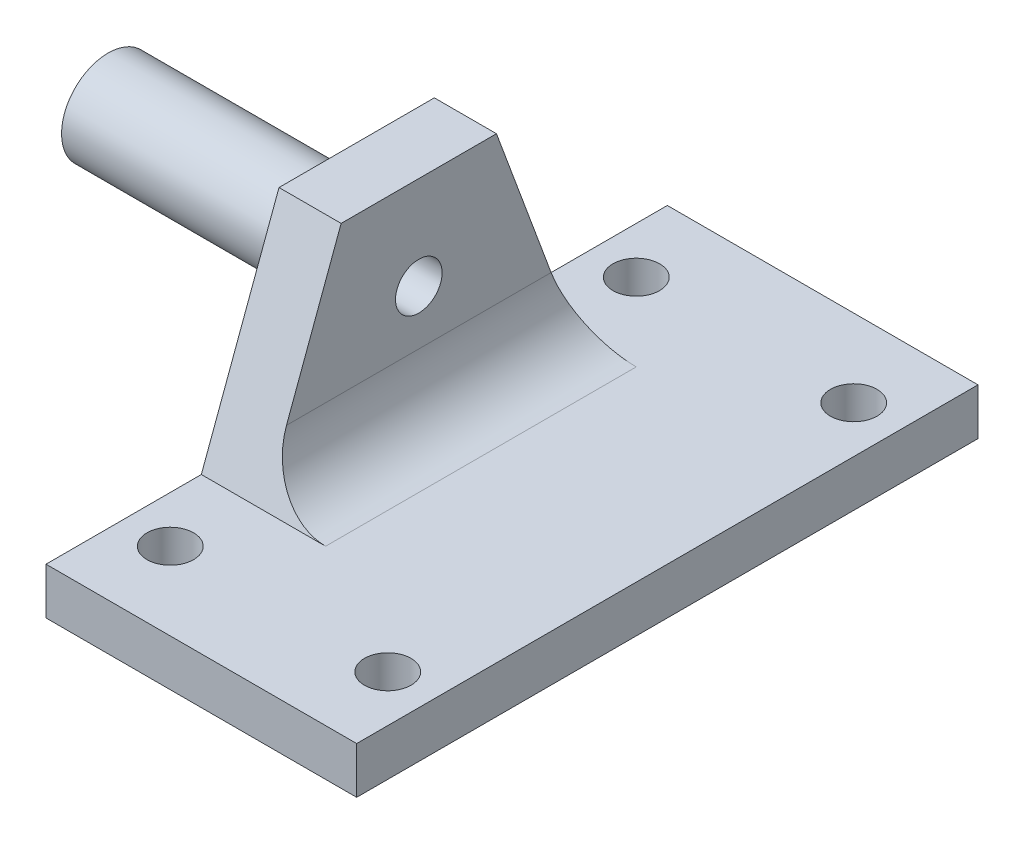
from build123d import *

# Parameters (mm, degrees)
SKETCH2_W           = 40
SKETCH2_H           = 3
BOSS_EXTRUDE1_DEPTH = 4
SKETCH3_W           = 40
SKETCH3_H           = 3
BOSS_EXTRUDE2_DEPTH = 16
SKETCH4_R           = 3
BOSS_EXTRUDE3_DEPTH = 16
SKETCH5_R           = 1.5
CUT_EXTRUDE1_DEPTH  = 37
SKETCH6_R           = 1.5
CUT_EXTRUDE2_DEPTH  = 4
FILLET1_R           = 4
FILLET2_R           = 2


with BuildPart() as part:
    # Sketch2 → Boss-Extrude1 (new body)
    with BuildSketch(Plane(origin=(0, 0, 0), x_dir=(0, 0, -1), z_dir=(1, 0, 0))):
        Polygon((-5, 15), (-10, 1.5), (10, 1.5), (5, 15), align=None)
        Rectangle(SKETCH2_W, SKETCH2_H)
    extrude(amount=BOSS_EXTRUDE1_DEPTH)

    # Sketch3 → Boss-Extrude2 (add)
    with BuildSketch(Plane(origin=(4, 0, 0), x_dir=(0, 0, -1), z_dir=(1, 0, 0))):
        Rectangle(SKETCH3_W, SKETCH3_H)
    extrude(amount=BOSS_EXTRUDE2_DEPTH)

    # Sketch4 → Boss-Extrude3 (add)
    with BuildSketch(Plane.ZY):
        with Locations((0, 9)):
            Circle(SKETCH4_R)
    extrude(amount=BOSS_EXTRUDE3_DEPTH)

    # Sketch5 → Cut-Extrude1 (cut, through all)
    with BuildSketch(Plane.ZY.offset(16)):
        with Locations((0, 9)):
            Circle(SKETCH5_R)
    extrude(amount=-CUT_EXTRUDE1_DEPTH, mode=Mode.SUBTRACT)

    # Sketch6 → Cut-Extrude2 (cut, through all)
    with BuildSketch(Plane(origin=(0, 1.5, 0), x_dir=(1, 0, 0), z_dir=(0, 1, 0))):
        with BuildLine():
            ThreePointArc((18.5, 15), (17, 16.5), (15.5, 15))
            Line((15.5, 15), (17, 15))
            Line((17, 15), (17, 13.5))
            ThreePointArc((17, 13.5), (18.060660172, 13.939339828), (18.5, 15))
        make_face()
        with BuildLine():
            Line((17, 15), (15.5, 15))
            ThreePointArc((15.5, 15), (15.939339828, 13.939339828), (17, 13.5))
            Line((17, 13.5), (17, 15))
        make_face()
        with BuildLine():
            ThreePointArc((18.5, -15), (18.060660172, -13.939339828), (17, -13.5))
            Line((17, -13.5), (17, -15))
            Line((17, -15), (15.5, -15))
            ThreePointArc((15.5, -15), (17, -16.5), (18.5, -15))
        make_face()
        with BuildLine():
            Line((17, -15), (17, -13.5))
            ThreePointArc((17, -13.5), (15.939339828, -13.939339828), (15.5, -15))
            Line((15.5, -15), (17, -15))
        make_face()
        with BuildLine():
            ThreePointArc((4.5, -15), (4.060660172, -13.939339828), (3, -13.5))
            Line((3, -13.5), (3, -15))
            Line((3, -15), (4.5, -15))
        make_face()
        with BuildLine():
            Line((3, -15), (3, -13.5))
            ThreePointArc((3, -13.5), (1.939339828, -16.060660172), (4.5, -15))
            Line((4.5, -15), (3, -15))
        make_face()
        with Locations((3, 15)):
            Circle(SKETCH6_R)
    extrude(amount=-CUT_EXTRUDE2_DEPTH, mode=Mode.SUBTRACT)

    # Fillet1
    fillet1_edges = [part.edges().sort_by_distance(p)[0] for p in [
        (4, 1.5, 0),
    ]]
    fillet(fillet1_edges, radius=FILLET1_R)

    # Fillet2
    fillet2_edges = [part.edges().sort_by_distance(p)[0] for p in [
        (0, 9, -3),
    ]]
    fillet(fillet2_edges, radius=FILLET2_R)


solid = part.part
